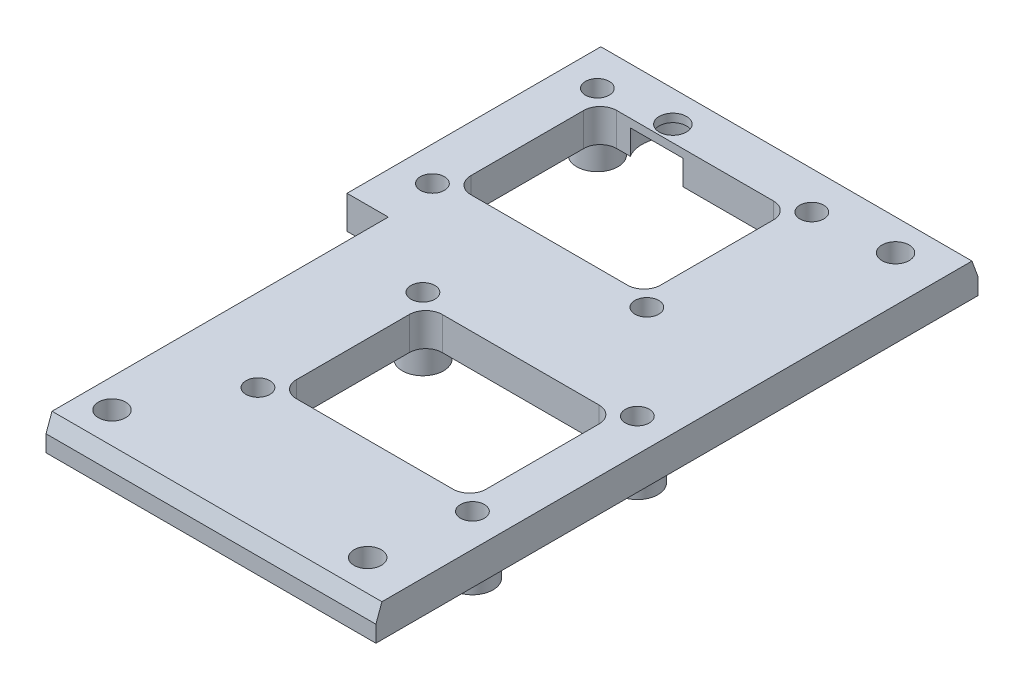
from build123d import *

# Parameters (mm, degrees)
SKETCH1_W             = 45
SKETCH1_H             = 74
SKETCH1_R             = 1.65
BOSS_EXTRUDE1_DEPTH   = 4
SKETCH3_R             = 3.75
CUT_EXTRUDE2_DEPTH    = 3
SKETCH4_W             = 5
SKETCH4_H             = 42
CUT_EXTRUDE3_DEPTH    = 5
SKETCH6_W             = 40
SKETCH6_H             = 0.5
SKETCH6_W_2           = 45
CUT_EXTRUDE4_DEPTH    = 5
CHAMFER1_SIZE         = 2
CHAMFER1_SIZE2        = 0.727940469
CHAMFER1_PART_2_SIZE  = 2
CHAMFER1_PART_2_SIZE2 = 0.727940469
SKETCH7_R             = 1.45
SKETCH7_W             = 23
SKETCH7_H             = 17.692307692
CUT_EXTRUDE5_DEPTH    = 5
FILLET1_R             = 2
SKETCH8_R             = 2.5
SKETCH8_R_2           = 1.45
BOSS_EXTRUDE2_DEPTH   = 3


with BuildPart() as part:
    # Sketch1 → Boss-Extrude1 (new body)
    with BuildSketch(Plane(origin=(0, 0, 0), x_dir=(1, 0, 0), z_dir=(0, 1, 0))):
        Rectangle(SKETCH1_W, SKETCH1_H)
        with Locations(Location((-10, 32, 0), (0, 0, 270))):  # turned: the seam where the file's is
            Circle(SKETCH1_R, mode=Mode.SUBTRACT)
        with Locations(Location((17, 32, 0), (0, 0, 270))):  # turned: the seam where the file's is
            Circle(SKETCH1_R, mode=Mode.SUBTRACT)
        with Locations(Location((-14, -32, 0), (0, 0, 270))):  # turned: the seam where the file's is
            Circle(SKETCH1_R, mode=Mode.SUBTRACT)
        with Locations(Location((17, -32, 0), (0, 0, 270))):  # turned: the seam where the file's is
            Circle(SKETCH1_R, mode=Mode.SUBTRACT)
    extrude(amount=BOSS_EXTRUDE1_DEPTH)

    # Sketch3 → Cut-Extrude2 (cut)
    with BuildSketch(Plane.XZ):
        with Locations(Location((-10, -32, 0), (0, 0, 270))):  # turned: the seam where the file's is
            Circle(SKETCH3_R)
    extrude(amount=-CUT_EXTRUDE2_DEPTH, mode=Mode.SUBTRACT)

    # Sketch4 → Cut-Extrude3 (cut, through all)
    with BuildSketch(Plane.XZ):
        with Locations((-20, 16)):
            Rectangle(SKETCH4_W, SKETCH4_H)
    extrude(amount=-CUT_EXTRUDE3_DEPTH, mode=Mode.SUBTRACT)

    # Sketch6 → Cut-Extrude4 (cut, through all)
    with BuildSketch(Plane.XZ):
        with Locations((2.5, 36.75)):
            Rectangle(SKETCH6_W, SKETCH6_H)
        with Locations((0, -36.75)):
            Rectangle(SKETCH6_W_2, SKETCH6_H)
    extrude(amount=-CUT_EXTRUDE4_DEPTH, mode=Mode.SUBTRACT)

    # Chamfer1
    chamfer1_edges = [part.edges().sort_by_distance(p)[0] for p in [
        (2.5, 4, 36.5),
    ]]
    chamfer1_side = [part.faces().sort_by_distance(p)[0] for p in [
        (2.5, 2, 36.5),
    ]]
    chamfer(chamfer1_edges, length=CHAMFER1_SIZE, length2=CHAMFER1_SIZE2, reference=chamfer1_side[0])

    # Chamfer1 part 2
    chamfer1_part_2_edges = [part.edges().sort_by_distance(p)[0] for p in [
        (0, 4, -36.5),
    ]]
    chamfer1_part_2_side = [part.faces().sort_by_distance(p)[0] for p in [
        (0, 2, -36.5),
    ]]
    chamfer(chamfer1_part_2_edges, length=CHAMFER1_PART_2_SIZE, length2=CHAMFER1_PART_2_SIZE2, reference=chamfer1_part_2_side[0])

    # Sketch7 → Cut-Extrude5 (cut, through all)
    with BuildSketch(Plane.XZ):
        with Locations(Location((-18.35, -31.2, 0), (0, 0, 270))):  # turned: the seam where the file's is
            Circle(SKETCH7_R)
        with Locations(Location((-18.35, -11.2, 0), (0, 0, 270))):  # turned: the seam where the file's is
            Circle(SKETCH7_R)
        with Locations(Location((7.65, -11.2, 0), (0, 0, 270))):  # turned: the seam where the file's is
            Circle(SKETCH7_R)
        with Locations(Location((7.65, -31.2, 0), (0, 0, 270))):  # turned: the seam where the file's is
            Circle(SKETCH7_R)
        with Locations(Location((18.5, 0.8, 0), (0, 0, 270))):  # turned: the seam where the file's is
            Circle(SKETCH7_R)
        with Locations(Location((-7.5, 0.8, 0), (0, 0, 270))):  # turned: the seam where the file's is
            Circle(SKETCH7_R)
        with Locations(Location((-7.5, 20.8, 0), (0, 0, 270))):  # turned: the seam where the file's is
            Circle(SKETCH7_R)
        with Locations(Location((18.5, 20.8, 0), (0, 0, 270))):  # turned: the seam where the file's is
            Circle(SKETCH7_R)
        with Locations((-5.35, -21.2)):
            Rectangle(SKETCH7_W, SKETCH7_H)
        with Locations((5.5, 10.8)):
            Rectangle(SKETCH7_W, SKETCH7_H)
    extrude(amount=-CUT_EXTRUDE5_DEPTH, mode=Mode.SUBTRACT)

    # Fillet1
    fillet1_edges = [part.edges().sort_by_distance(p)[0] for p in [
        (6.15, 2, -30.046153846),
        (-16.85, 2, -30.046153846),
        (-16.85, 2, -12.353846154),
        (6.15, 2, -12.353846154),
        (-6, 2, 1.953846154),
        (-6, 2, 19.646153846),
        (17, 2, 19.646153846),
        (17, 2, 1.953846154),
    ]]
    fillet(fillet1_edges, radius=FILLET1_R)

    # Sketch8 → Boss-Extrude2 (add)
    with BuildSketch(Plane.XZ):
        with Locations(Location((-18.35, -11.2, 0), (0, 0, 90))):  # turned: the seam where the file's is
            Circle(SKETCH8_R)
        with Locations(Location((-18.35, -11.2, 0), (0, 0, 270))):  # turned: the seam where the file's is
            Circle(SKETCH8_R_2, mode=Mode.SUBTRACT)
        with Locations(Location((-18.35, -31.2, 0), (0, 0, 90))):  # turned: the seam where the file's is
            Circle(SKETCH8_R)
        with Locations(Location((-18.35, -31.2, 0), (0, 0, 270))):  # turned: the seam where the file's is
            Circle(SKETCH8_R_2, mode=Mode.SUBTRACT)
        with Locations(Location((7.65, -11.2, 0), (0, 0, 90))):  # turned: the seam where the file's is
            Circle(SKETCH8_R)
        with Locations(Location((7.65, -11.2, 0), (0, 0, 270))):  # turned: the seam where the file's is
            Circle(SKETCH8_R_2, mode=Mode.SUBTRACT)
        with Locations(Location((7.65, -31.2, 0), (0, 0, 90))):  # turned: the seam where the file's is
            Circle(SKETCH8_R)
        with Locations(Location((7.65, -31.2, 0), (0, 0, 270))):  # turned: the seam where the file's is
            Circle(SKETCH8_R_2, mode=Mode.SUBTRACT)
        with Locations(Location((18.5, 0.8, 0), (0, 0, 90))):  # turned: the seam where the file's is
            Circle(SKETCH8_R)
        with Locations(Location((18.5, 0.8, 0), (0, 0, 270))):  # turned: the seam where the file's is
            Circle(SKETCH8_R_2, mode=Mode.SUBTRACT)
        with Locations(Location((-7.5, 0.8, 0), (0, 0, 90))):  # turned: the seam where the file's is
            Circle(SKETCH8_R)
        with Locations(Location((-7.5, 0.8, 0), (0, 0, 270))):  # turned: the seam where the file's is
            Circle(SKETCH8_R_2, mode=Mode.SUBTRACT)
        with Locations(Location((-7.5, 20.8, 0), (0, 0, 90))):  # turned: the seam where the file's is
            Circle(SKETCH8_R)
        with Locations(Location((-7.5, 20.8, 0), (0, 0, 270))):  # turned: the seam where the file's is
            Circle(SKETCH8_R_2, mode=Mode.SUBTRACT)
        with Locations(Location((18.5, 20.8, 0), (0, 0, 90))):  # turned: the seam where the file's is
            Circle(SKETCH8_R)
        with Locations(Location((18.5, 20.8, 0), (0, 0, 270))):  # turned: the seam where the file's is
            Circle(SKETCH8_R_2, mode=Mode.SUBTRACT)
    extrude(amount=BOSS_EXTRUDE2_DEPTH)


solid = part.part
